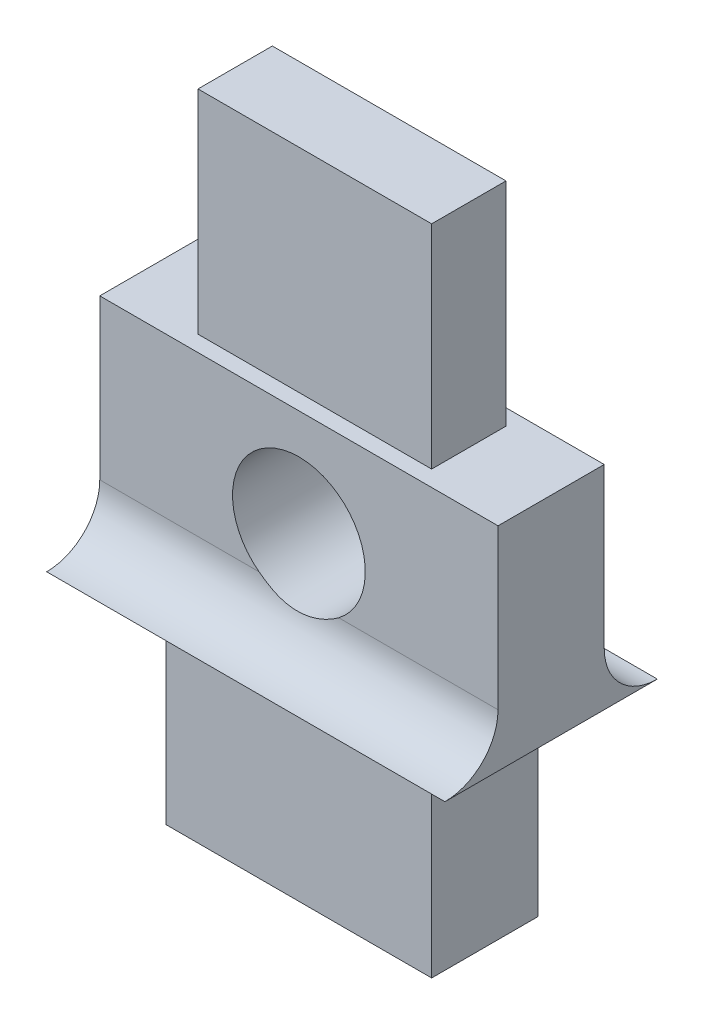
from build123d import *

# Parameters (mm, degrees)
SKETCH1_R               = 1.25
BOSS_EXTRUDE1_DEPTH     = 2
BOSS_EXTRUDE2_DEPTH     = 7.5
SKETCH3_R               = 1.25
CUT_EXTRUDE1_DEPTH      = 2
CUT_EXTRUDE1_DEPTH_BACK = 4
SKETCH4_W               = 5
SKETCH4_H               = 2
SKETCH4_W_2             = 4.4
SKETCH4_H_2             = 1.4
CUT_EXTRUDE2_DEPTH      = 4


with BuildPart() as part:
    # Sketch1 → Boss-Extrude1 (new body)
    with BuildSketch(Plane.XY):
        Polygon((1952.176808721, 1466.884115951), (1957.176808721, 1466.884115951), (1957.176808721, 1462.884115951), (1958.426808721, 1462.884115951), (1958.426808721, 1458.884115951), (1957.176808721, 1458.884115951), (1957.176808721, 1454.884115951), (1952.176808721, 1454.884115951), (1952.176808721, 1458.884115951), (1950.926808721, 1458.884115951), (1950.926808721, 1462.884115951), (1952.176808721, 1462.884115951), align=None)
        with Locations((1954.676808721, 1460.884115951)):
            Circle(SKETCH1_R, mode=Mode.SUBTRACT)
    extrude(amount=BOSS_EXTRUDE1_DEPTH)

    # Sketch2 → Boss-Extrude2 (add)
    with BuildSketch(Plane.ZY.offset(-1950.926808721)):
        with BuildLine():
            Line((2, 1458.884115951), (2, 1459.884115951))
            ThreePointArc((2, 1459.884115951), (2.292893219, 1459.17700917), (3, 1458.884115951))
            Line((3, 1458.884115951), (2, 1458.884115951))
        make_face()
        with BuildLine():
            Line((0, 1458.884115951), (-1, 1458.884115951))
            ThreePointArc((-1, 1458.884115951), (-0.292893219, 1459.17700917), (0, 1459.884115951))
            Line((0, 1459.884115951), (0, 1458.884115951))
        make_face()
    extrude(amount=-BOSS_EXTRUDE2_DEPTH)

    # Sketch3 → Cut-Extrude1 (cut, two sides)
    with BuildSketch(Plane.XY.offset(2)) as cut_extrude1_sk:
        with Locations((1954.676808721, 1460.884115951)):
            Circle(SKETCH3_R)
    extrude(amount=CUT_EXTRUDE1_DEPTH, mode=Mode.SUBTRACT)
    extrude(cut_extrude1_sk.sketch, amount=-CUT_EXTRUDE1_DEPTH_BACK, mode=Mode.SUBTRACT)

    # Sketch4 → Cut-Extrude2 (cut)
    with BuildSketch(Plane(origin=(0, 1466.884115951, 0), x_dir=(1, 0, 0), z_dir=(0, 1, 0))):
        with Locations((1954.676808721, -1)):
            Rectangle(SKETCH4_W, SKETCH4_H)
        with Locations((1954.676808721, -1)):
            Rectangle(SKETCH4_W_2, SKETCH4_H_2, mode=Mode.SUBTRACT)
    extrude(amount=-CUT_EXTRUDE2_DEPTH, mode=Mode.SUBTRACT)


solid = part.part
